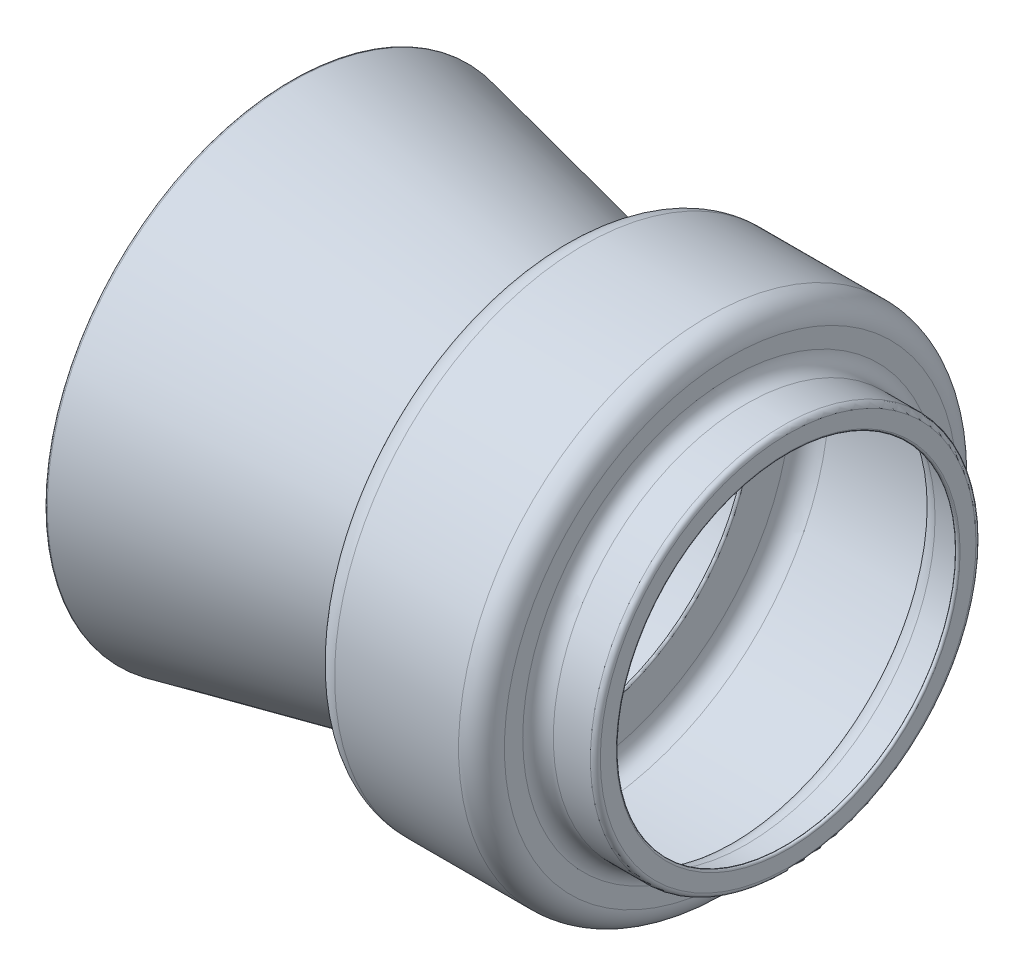
from build123d import *

# Parameters (mm, degrees)
SCALE1_SCALE = 10
SCALE2_SCALE = 0.75


with BuildPart() as part:
    # Sketch1 → Revolve1 (revolve)
    with BuildSketch(Plane.XY):
        with BuildLine():
            Line((0, 45), (0, 49.15))
            ThreePointArc((0, 49.15), (-0.380761184, 50.069238816), (-1.3, 50.45))
            Line((-1.3, 50.45), (-11, 50.45))
            ThreePointArc((-11, 50.45), (-13.828427125, 51.621572875), (-15, 54.45))
            Line((-15, 54.45), (-15, 59.25))
            ThreePointArc((-15, 59.25), (-16.757359313, 63.492640687), (-21, 65.25))
            Line((-21, 65.25), (-53.44, 65.25))
            ThreePointArc((-53.44, 65.25), (-57.682640687, 63.492640687), (-59.44, 59.25))
            Line((-59.44, 59.25), (-59.44, 49.57))
            Line((-59.44, 49.57), (-129.44, 64.448959317))
            ThreePointArc((-129.44, 64.448959317), (-130.033029646, 64.063841362), (-129.647911691, 63.470811716))
            Line((-129.647911691, 63.470811716), (-59.043955845, 48.463477621))
            ThreePointArc((-59.043955845, 48.463477621), (-58.625339804, 48.563978441), (-58.44, 48.952551422))
            Line((-58.44, 48.952551422), (-58.44, 59.25))
            ThreePointArc((-58.44, 59.25), (-56.975533906, 62.785533906), (-53.44, 64.25))
            Line((-53.44, 64.25), (-21, 64.25))
            ThreePointArc((-21, 64.25), (-17.464466094, 62.785533906), (-16, 59.25))
            Line((-16, 59.25), (-16, 54.45))
            ThreePointArc((-16, 54.45), (-14.535533906, 50.914466094), (-11, 49.45))
            Line((-11, 49.45), (-1.3, 49.45))
            ThreePointArc((-1.3, 49.45), (-1.087867966, 49.362132034), (-1, 49.15))
            Line((-1, 49.15), (-1, 45))
            ThreePointArc((-1, 45), (-0.5, 44.5), (0, 45))
        make_face()
    revolve(axis=Axis((0, 0, 0), (-1, 0, 0)))


with BuildPart() as part_1:
    # Scale1: scaled about (-60.336714815, 0, 0)
    add(part.part.scale(SCALE1_SCALE).moved(Location((543.030433335, 0, 0))))


with BuildPart() as part_2:
    # Scale2: scaled about (0, 0, 0)
    add(part_1.part.scale(SCALE2_SCALE))


solid = part_2.part
